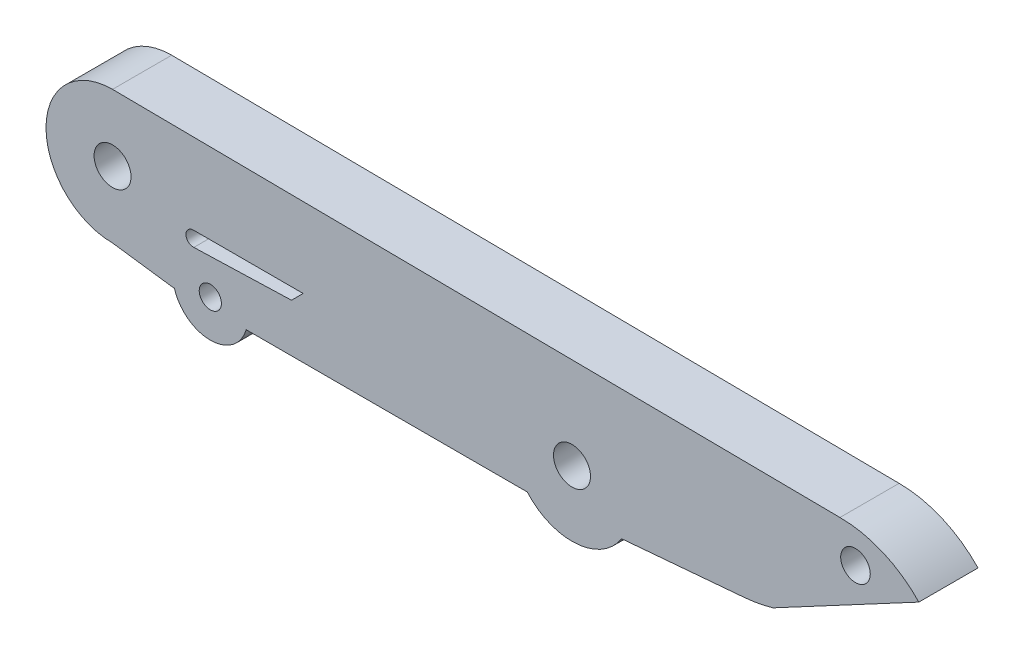
from build123d import *

# Parameters (mm, degrees)
SKETCH1_R           = 0.75
SKETCH1_R_2         = 1.25
SKETCH1_R_3         = 1
BOSS_EXTRUDE1_DEPTH = 4


with BuildPart() as part:
    # Sketch1 → Boss-Extrude1 (new body)
    with BuildSketch(Plane.XY):
        with BuildLine():
            ThreePointArc((46.980351469, -3.99295605), (47.960883487, -3.859840066), (48.923458954, -3.63046837))
            Line((48.923458954, -3.63046837), (58.781132355, 1.635320677))
            ThreePointArc((58.781132355, 1.635320677), (56.34843078, 3.327817207), (53.445513313, 3.924182561))
            Line((53.445513313, 3.924182561), (4.34174303, 4.401750396))
            Line((4.34174303, 4.401750396), (4.254220138, 4.402601616))
            ThreePointArc((4.254220138, 4.402601616), (-0.245779862, -0.097398384), (4.254220138, -4.597398384))
            Line((4.254220138, -4.597398384), (8.346946684, -5.15524466))
            Line((8.346946684, -5.15524466), (8.439838836, -5.15524466))
            ThreePointArc((8.439838836, -5.15524466), (10.866040294, -6.980836707), (13.292241752, -5.15524466))
            Line((13.292241752, -5.15524466), (24.292241752, -5.15524466))
            Line((24.292241752, -5.15524466), (32.304248164, -5.15524466))
            ThreePointArc((32.304248164, -5.15524466), (35.607637679, -6.523335594), (38.685278543, -4.70339554))
            Line((38.685278543, -4.70339554), (46.980351469, -3.99295605))
        make_face()
        with Locations((10.866040294, -4.455836707)):
            Circle(SKETCH1_R, mode=Mode.SUBTRACT)
        with BuildLine():
            ThreePointArc((9.719017648, -2.106433547), (9.219017648, -1.606433547), (9.719017648, -1.106433547))
            Line((9.719017648, -1.106433547), (17.146734956, -1.106433547))
            Line((17.146734956, -1.106433547), (16.355916602, -1.897251901))
            Line((16.355916602, -1.897251901), (9.750504349, -2.10544115))
            ThreePointArc((9.750504349, -2.10544115), (9.734768816, -2.106185386), (9.719017648, -2.106433547))
        make_face(mode=Mode.SUBTRACT)
        with Locations((35.325099909, -2.10544115)):
            Circle(SKETCH1_R_2, mode=Mode.SUBTRACT)
        with Locations((4.254220138, -0.097398384)):
            Circle(SKETCH1_R_2, mode=Mode.SUBTRACT)
        with Locations((54.495894224, 1.635320677)):
            Circle(SKETCH1_R_3, mode=Mode.SUBTRACT)
    extrude(amount=BOSS_EXTRUDE1_DEPTH)


solid = part.part
